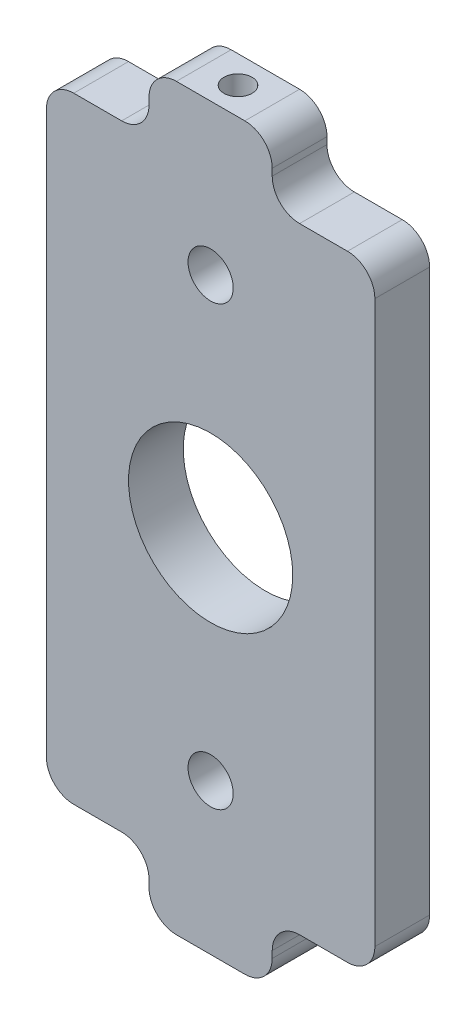
from build123d import *

# Parameters (mm, degrees)
SKETCH_3_R             = 6
EXTRUDE_1_DEPTH        = 4
FILLET_1_R             = 2
HOLE_WIZARD_M4_2_D     = 3.3
HOLE_WIZARD_M4_2_DEPTH = 11.5
HOLE_WIZARD_M4_2_TIP   = 0.991420021


with BuildPart() as part:
    # 草图3 → 凸台-拉伸1 (new body)
    with BuildSketch(Plane.XY):
        with BuildLine():
            Line((-2.5, -27), (2.5, -27))
            ThreePointArc((2.5, -27), (3.914213562, -26.414213562), (4.5, -25))
            Line((4.5, -25), (4.5, -24.5))
            ThreePointArc((4.5, -24.5), (5.085786438, -23.085786438), (6.5, -22.5))
            Line((6.5, -22.5), (10, -22.5))
            ThreePointArc((10, -22.5), (11.414213562, -21.914213562), (12, -20.5))
            Line((12, -20.5), (12, 20.5))
            ThreePointArc((12, 20.5), (11.414213562, 21.914213562), (10, 22.5))
            Line((10, 22.5), (4.5, 22.5))
            Line((4.5, 22.5), (4.5, 25))
            ThreePointArc((4.5, 25), (3.914213562, 26.414213562), (2.5, 27))
            Line((2.5, 27), (-2.5, 27))
            ThreePointArc((-2.5, 27), (-3.914213562, 26.414213562), (-4.5, 25))
            Line((-4.5, 25), (-4.5, 22.5))
            Line((-4.5, 22.5), (-10, 22.5))
            ThreePointArc((-10, 22.5), (-11.414213562, 21.914213562), (-12, 20.5))
            Line((-12, 20.5), (-12, -20.5))
            ThreePointArc((-12, -20.5), (-11.414213562, -21.914213562), (-10, -22.5))
            Line((-10, -22.5), (-6.5, -22.5))
            ThreePointArc((-6.5, -22.5), (-5.085786438, -23.085786438), (-4.5, -24.5))
            Line((-4.5, -24.5), (-4.5, -25))
            ThreePointArc((-4.5, -25), (-3.914213562, -26.414213562), (-2.5, -27))
        make_face()
        Circle(SKETCH_3_R, mode=Mode.SUBTRACT)
    extrude(amount=EXTRUDE_1_DEPTH)

    # 草图6 → M2.5 螺纹孔1 (revolve, cut)
    with BuildSketch(Plane(origin=(0, 27, 2), x_dir=(0, 0, 1), z_dir=(1, 0, 0))):
        Polygon((0, 0), (0, 7.865882135), (1.025, 7.25), (1.025, 0), align=None)
    hole_wizard_m2_5_1 = revolve(axis=Axis((0, 33.35, 2), (0, -1, 0)), mode=Mode.SUBTRACT)

    # 镜向1: M2.5 螺纹孔1 across plane
    add(hole_wizard_m2_5_1.mirror(Plane.ZX), mode=Mode.SUBTRACT)

    # 圆角1
    fillet_1_edges = [part.edges().sort_by_distance(p)[0] for p in [
        (-4.5, 22.5, 2),
        (4.5, 22.5, 2),
    ]]
    fillet(fillet_1_edges, radius=FILLET_1_R)

    # M4 螺纹孔2
    with Locations(Plane(origin=(0, 0, 0), x_dir=(-1, 0, 0), z_dir=(0, 0, -1))):
        with Locations((0, 16), (0, -16)):
            Hole(HOLE_WIZARD_M4_2_D / 2, depth=HOLE_WIZARD_M4_2_DEPTH)
            with Locations((0, 0, -(HOLE_WIZARD_M4_2_DEPTH + HOLE_WIZARD_M4_2_TIP / 2))):  # 118° drill point
                Cone(0, HOLE_WIZARD_M4_2_D / 2, HOLE_WIZARD_M4_2_TIP, mode=Mode.SUBTRACT)


solid = part.part
